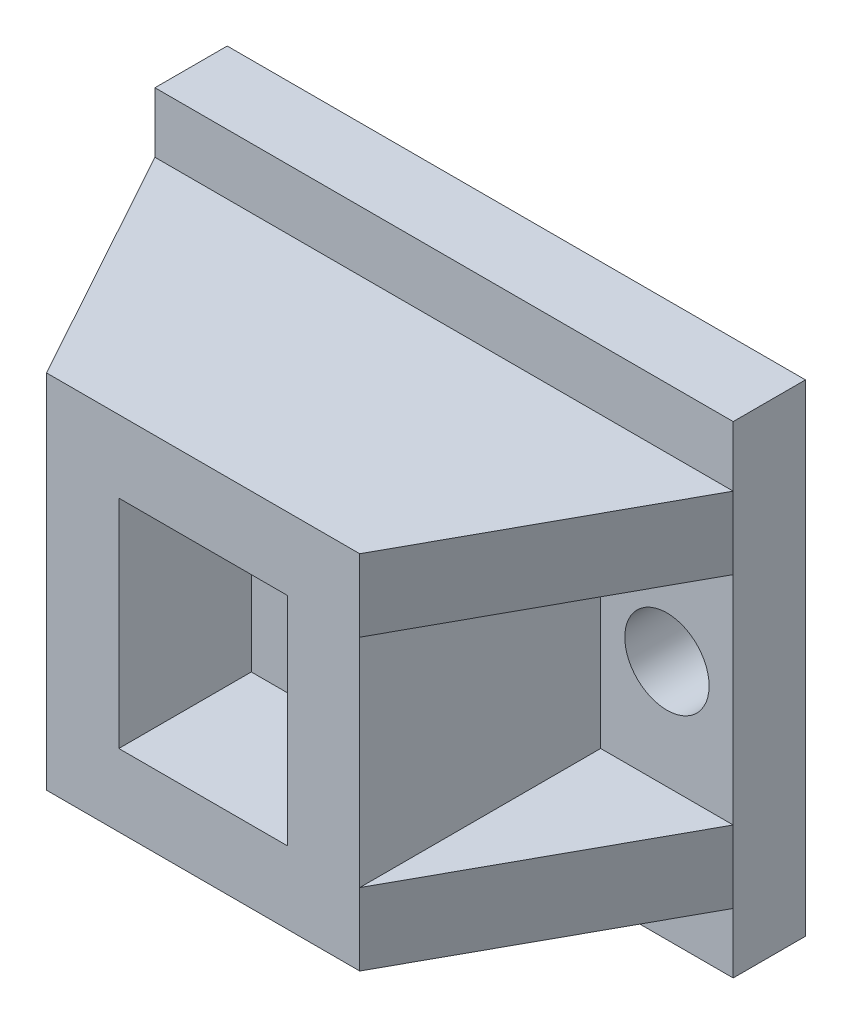
from build123d import *

# Parameters (mm, degrees)
ESQUISSE1_W               = 24
ESQUISSE1_H               = 20
ESQUISSE1_W_2             = 13
ESQUISSE1_H_2             = 15
ESQUISSE1_R               = 1.75
BOSS_EXTRU_1_DEPTH        = 3
ESQUISSE1_3_W             = 13
ESQUISSE1_3_H             = 15
ESQUISSE1_3_W_2           = 7
ESQUISSE1_3_H_2           = 9
BOSS_EXTRU_2_DEPTH        = 13
NERVURE2_REACH            = 26.885
ESQUISSE5_WALL_W          = 63.182180764
ESQUISSE5_WALL_H          = 3
SYM_TRIE5_COPY_1_REACH    = 26.885
SYM_TRIE5_COPY_1_SKETCH_W = 63.182180764
SYM_TRIE5_COPY_1_SKETCH_H = 3
ESQUISSE1_4_W             = 7
ESQUISSE1_4_H             = 9
BOSS_EXTRU_3_DEPTH        = 7.5


with BuildPart() as part:
    # Esquisse1 → Boss.-Extru.1 (new body)
    with BuildSketch(Plane.XY):
        Rectangle(ESQUISSE1_W, ESQUISSE1_H)
        Rectangle(ESQUISSE1_W_2, ESQUISSE1_H_2, mode=Mode.SUBTRACT)
        with Locations((-9.25, 0)):
            Circle(ESQUISSE1_R, mode=Mode.SUBTRACT)
        with Locations((9.25, 0)):
            Circle(ESQUISSE1_R, mode=Mode.SUBTRACT)
    extrude(amount=BOSS_EXTRU_1_DEPTH)

    # Esquisse1_3 → Boss.-Extru.2 (add)
    with BuildSketch(Plane.XY):
        Rectangle(ESQUISSE1_3_W, ESQUISSE1_3_H)
        Rectangle(ESQUISSE1_3_W_2, ESQUISSE1_3_H_2, mode=Mode.SUBTRACT)
    extrude(amount=BOSS_EXTRU_2_DEPTH)

    # Esquisse5 wall → Nervure2 (add, up to next)
    with BuildSketch(Plane(origin=(-9.25, -7.5, 8), x_dir=(-0.481918749772, 0, -0.876215908677), z_dir=(0.876215908677, 0, -0.481918749772)), mode=Mode.PRIVATE) as nervure2_sk1:
        with Locations((0, 1.5)):
            Rectangle(ESQUISSE5_WALL_W, ESQUISSE5_WALL_H)
    nervure2_tool1 = extrude(nervure2_sk1.sketch, amount=NERVURE2_REACH, mode=Mode.PRIVATE) - part.part
    nervure2 = nervure2_tool1.solids().sort_by_distance((-9.25, -7.5, 8))[0]
    add(nervure2)

    # Symétrie4: Nervure2 across plane
    add(nervure2.mirror(Plane.ZX))

    # Symétrie5: Nervure2 across plane
    add(nervure2.mirror(Plane(origin=(0, 0, 0), x_dir=(0, 0, 1), z_dir=(1, 0, 0))))

    # Symétrie5 copy 1 sketch → Symétrie5 copy 1 (add, up to next)
    with BuildSketch(Plane(origin=(9.25, 7.5, 8), x_dir=(0.481918749772, 0, -0.876215908677), z_dir=(-0.876215908677, 0, -0.481918749772)), mode=Mode.PRIVATE) as sym_trie5_copy_1_sk1:
        with Locations((0, 1.5)):
            Rectangle(SYM_TRIE5_COPY_1_SKETCH_W, SYM_TRIE5_COPY_1_SKETCH_H)
    sym_trie5_copy_1_tool1 = extrude(sym_trie5_copy_1_sk1.sketch, amount=SYM_TRIE5_COPY_1_REACH, mode=Mode.PRIVATE) - part.part
    add(sym_trie5_copy_1_tool1.solids().sort_by_distance((9.25, 7.5, 8))[0])

    # Esquisse1_4 → Boss.-Extru.3 (add)
    with BuildSketch(Plane.XY):
        Rectangle(ESQUISSE1_4_W, ESQUISSE1_4_H)
    extrude(amount=BOSS_EXTRU_3_DEPTH)


solid = part.part
